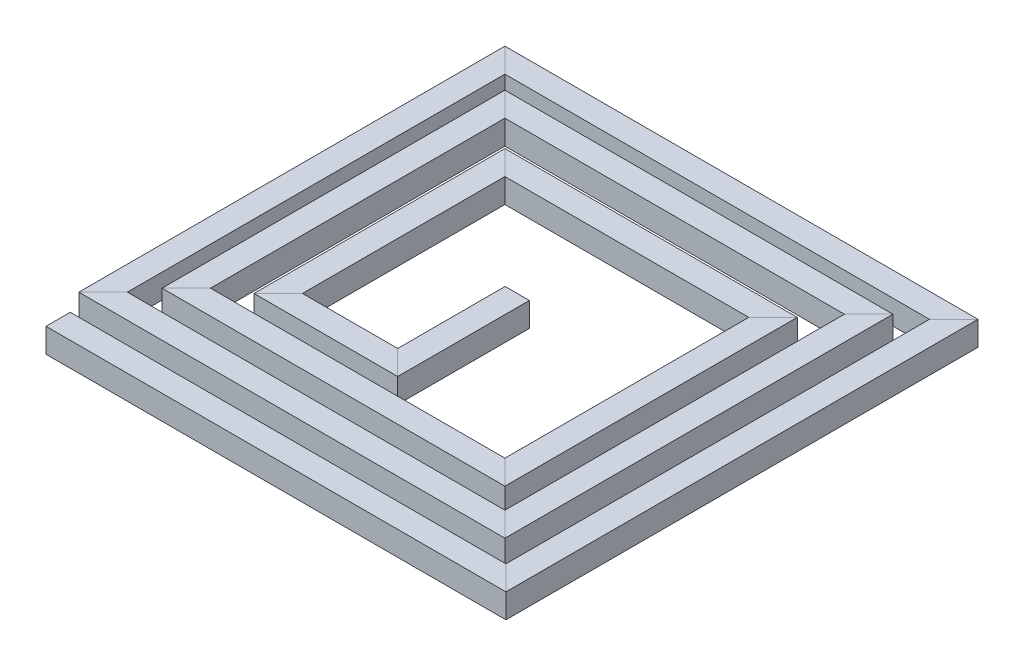
from build123d import *

# Parameters (mm, degrees)
SKETCH3_W = 7.046537748
SKETCH3_H = 7.046537748


with BuildPart() as part:
    # Sweep1: sweep along a path in Sketch2
    with BuildLine(Plane(origin=(0, 0, 0), x_dir=(1, 0, 0), z_dir=(0, 1, 0))) as sweep1_path:
        Line((-56.433512337, -33.614206506), (73.671403243, -33.614206506))
        Line((73.671403243, -33.614206506), (73.671403243, 96.490709074))
        Line((73.671403243, 96.490709074), (-56.731082257, 96.490709074))
        Line((-56.731082257, 96.490709074), (-56.731082257, -20.265698264))
        Line((-56.731082257, -20.265698264), (60.025325081, -20.265698264))
        Line((60.025325081, -20.265698264), (60.025325081, 85.412146694))
        Line((60.025325081, 85.412146694), (-45.652519877, 85.412146694))
        Line((-45.652519877, 85.412146694), (-45.652519877, -7.17127309))
        Line((-45.652519877, -7.17127309), (46.930899908, -7.17127309))
        Line((46.930899908, -7.17127309), (46.930899908, 70.729135959))
        Line((46.930899908, 70.729135959), (-30.969509142, 70.729135959))
        Line((-30.969509142, 70.729135959), (-30.969509142, 4.853856027))
        Line((-30.969509142, 4.853856027), (3.758736239, 4.853856027))
        Line((3.758736239, 4.853856027), (3.758736239, 39.582101408))
    # Sketch3 → Sweep1 (sweep)
    with BuildSketch(Plane(origin=(-56.433512337, 0, 0), x_dir=(0, 0, -1), z_dir=(1, 0, 0))):
        with Locations((-33.614206506, 0)):
            Rectangle(SKETCH3_W, SKETCH3_H)
    sweep(path=sweep1_path.line, transition=Transition.RIGHT)


solid = part.part
